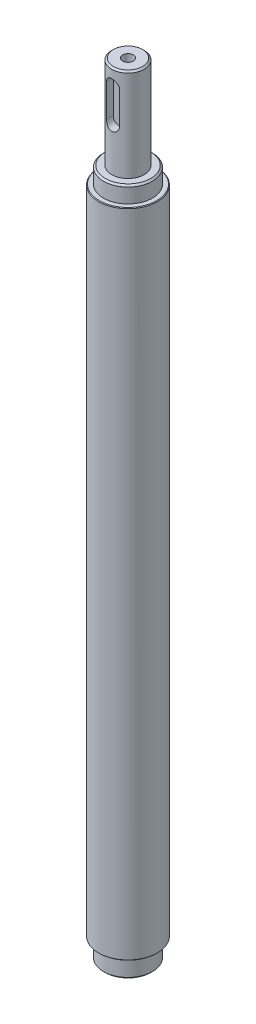
from build123d import *

# Parameters (mm, degrees)
CHAMFER_1_SIZE                 = 0.5
CHAMFER_2_SIZE                 = 0.2
HOLE_WIZARD_6_0_6_1_AT_2_COUNT = 2
HOLE_WIZARD_6_0_6_1_AT_2_PITCH = 48
HOLE_WIZARD_6_0_6_1_AT_3_COUNT = 2
HOLE_WIZARD_6_0_6_1_AT_3_PITCH = 113
HOLE_WIZARD_6_0_6_1_AT_4_COUNT = 2
HOLE_WIZARD_6_0_6_1_AT_4_PITCH = 161
PATTERN_CIRCULAR_1_COUNT       = 2
PATTERN_CIRCULAR_1_ANGLE       = 90
CUT_EXTRUDE_3_DEPTH            = 10
HOLE_WIZARD_M4_1_D             = 3.3
HOLE_WIZARD_M4_1_DEPTH         = 11.5
HOLE_WIZARD_M4_1_TIP           = 0.991420021


with BuildPart() as part:
    # 草图1 → 旋转1 (revolve)
    with BuildSketch(Plane.XY):
        Polygon((0, 0), (0, -239.5), (-7.5, -239.5), (-7.5, -233.5), (-9, -233.5), (-9, -33.5), (-7.5, -33.5), (-7.5, -28.5), (-5, -28.5), (-5, 0), align=None)
    revolve(axis=Axis((0, 0, 0), (0, -1, 0)))

    # 倒角1
    chamfer_1_edges = [part.edges().sort_by_distance(p)[0] for p in [
        (7.5, -239.5, 0),
        (5, 0, 0),
        (7.5, -28.5, 0),
    ]]
    chamfer(chamfer_1_edges, length=CHAMFER_1_SIZE)

    # 倒角2
    chamfer_2_edges = [part.edges().sort_by_distance(p)[0] for p in [
        (9, -33.5, 0),
        (9, -233.5, 0),
    ]]
    chamfer(chamfer_2_edges, length=CHAMFER_2_SIZE)

    # 草图5 → Ø6.0 (6) 直径孔1 (revolve, cut)
    with BuildSketch(Plane(origin=(0, -214, -9), x_dir=(0, 1, 0), z_dir=(1, 0, 0))):
        Polygon((0, 0), (0, 3.802581857), (3, 2), (3, 0), align=None)
    hole_wizard_6_0_6_1 = revolve(axis=Axis((0, -214, -15.35), (0, 0, 1)), mode=Mode.SUBTRACT)

    # Ø6.0 (6) 直径孔1 at 2: Ø6.0 (6) 直径孔1 ×2
    with Locations(*[(0, i * HOLE_WIZARD_6_0_6_1_AT_2_PITCH, 0) for i in range(1, HOLE_WIZARD_6_0_6_1_AT_2_COUNT)]):
        add(hole_wizard_6_0_6_1, mode=Mode.SUBTRACT)

    # Ø6.0 (6) 直径孔1 at 3: Ø6.0 (6) 直径孔1 ×2
    with Locations(*[(0, i * HOLE_WIZARD_6_0_6_1_AT_3_PITCH, 0) for i in range(1, HOLE_WIZARD_6_0_6_1_AT_3_COUNT)]):
        add(hole_wizard_6_0_6_1, mode=Mode.SUBTRACT)

    # Ø6.0 (6) 直径孔1 at 4: Ø6.0 (6) 直径孔1 ×2
    with Locations(*[(0, i * HOLE_WIZARD_6_0_6_1_AT_4_PITCH, 0) for i in range(1, HOLE_WIZARD_6_0_6_1_AT_4_COUNT)]):
        add(hole_wizard_6_0_6_1, mode=Mode.SUBTRACT)

    # 阵列(圆周)1: Ø6.0 (6) 直径孔1 ×2 about axis
    pattern_circular_1_axis = Axis((0, 0, 0), (0, 1, 0))
    for i in range(1, PATTERN_CIRCULAR_1_COUNT):
        add(hole_wizard_6_0_6_1.rotate(pattern_circular_1_axis, i * PATTERN_CIRCULAR_1_ANGLE / (PATTERN_CIRCULAR_1_COUNT - 1)), mode=Mode.SUBTRACT)

    # 阵列(圆周)1 copy 1 sketch → 阵列(圆周)1 copy 1 (revolve, cut)
    with BuildSketch(Plane(origin=(-9, -166, 0), x_dir=(0, 1, 0), z_dir=(0, 0, -1))):
        Polygon((0, 0), (0, 3.802581857), (3, 2), (3, 0), align=None)
    revolve(axis=Axis((-15.35, -166, 0), (1, 0, 0)), mode=Mode.SUBTRACT)

    # 阵列(圆周)1 copy 2 sketch → 阵列(圆周)1 copy 2 (revolve, cut)
    with BuildSketch(Plane(origin=(-9, -101, 0), x_dir=(0, 1, 0), z_dir=(0, 0, -1))):
        Polygon((0, 0), (0, 3.802581857), (3, 2), (3, 0), align=None)
    revolve(axis=Axis((-15.35, -101, 0), (1, 0, 0)), mode=Mode.SUBTRACT)

    # 阵列(圆周)1 copy 3 sketch → 阵列(圆周)1 copy 3 (revolve, cut)
    with BuildSketch(Plane(origin=(-9, -53, 0), x_dir=(0, 1, 0), z_dir=(0, 0, -1))):
        Polygon((0, 0), (0, 3.802581857), (3, 2), (3, 0), align=None)
    revolve(axis=Axis((-15.35, -53, 0), (1, 0, 0)), mode=Mode.SUBTRACT)

    # 草图7 → 切除-拉伸3 (cut)
    with BuildSketch(Plane.XY.offset(2.5)):
        with BuildLine():
            Line((2, -5), (2, -15))
            ThreePointArc((2, -15), (0, -17), (-2, -15))
            Line((-2, -15), (-2, -5))
            ThreePointArc((-2, -5), (0, -3), (2, -5))
        make_face()
    extrude(amount=CUT_EXTRUDE_3_DEPTH, mode=Mode.SUBTRACT)

    # M4 螺纹孔1
    with Locations(Plane(origin=(0, 0, 0), x_dir=(1, 0, 0), z_dir=(0, 1, 0))):
        with Locations((0, 0)):
            Hole(HOLE_WIZARD_M4_1_D / 2, depth=HOLE_WIZARD_M4_1_DEPTH)
            with Locations((0, 0, -(HOLE_WIZARD_M4_1_DEPTH + HOLE_WIZARD_M4_1_TIP / 2))):  # 118° drill point
                Cone(0, HOLE_WIZARD_M4_1_D / 2, HOLE_WIZARD_M4_1_TIP, mode=Mode.SUBTRACT)


solid = part.part
